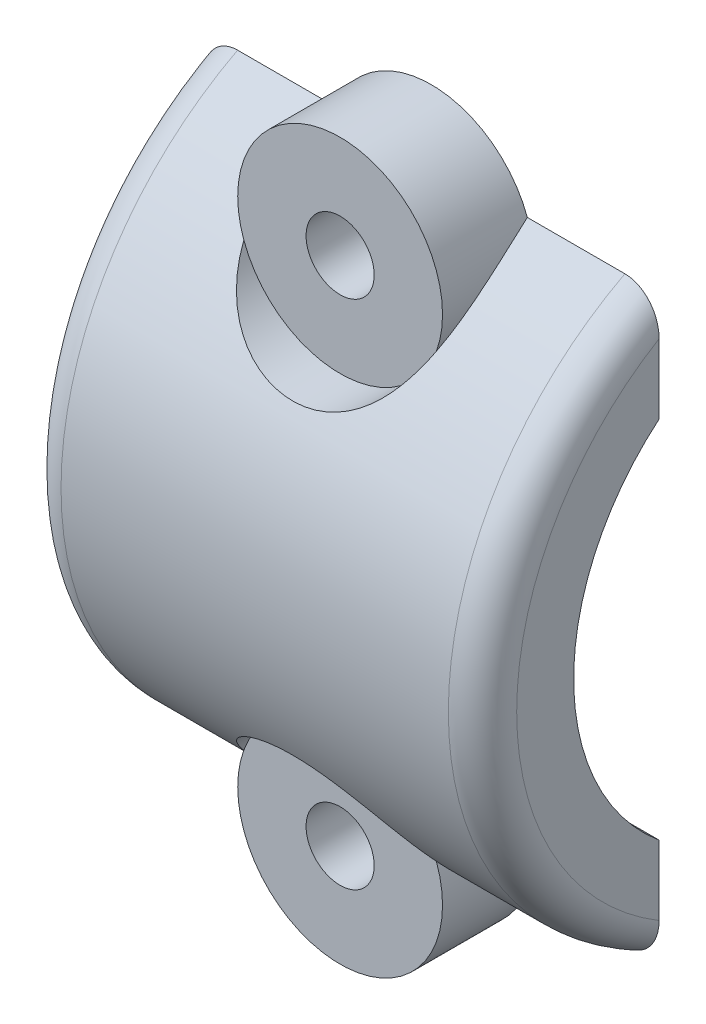
from build123d import *

# Parameters (mm, degrees)
BOSS_EXTRUDE2_DEPTH = 25.4
CUT_EXTRUDE7_START  = -1
SKETCH5_5_R         = 1.89865
CUT_EXTRUDE7_DEPTH  = 11.8425
SKETCH8_R           = 5.70865
SKETCH8_R_2         = 1.89865
BOSS_EXTRUDE4_DEPTH = 5.08
CUT_EXTRUDE8_START  = 5.08
SKETCH8_3_R         = 5.70865
SKETCH8_3_R_2       = 1.89865
CUT_EXTRUDE8_DEPTH  = 5.7625001
CUT_EXTRUDE3_DEPTH  = 26.4000001
FILLET3_R           = 1.905


with BuildPart() as part:
    # Sketch4 → Boss-Extrude2 (new body)
    with BuildSketch(Plane(origin=(-23.495, 41.0349954, 0), x_dir=(0, 0, 1), z_dir=(-1, 0, 0))):
        with BuildLine():
            ThreePointArc((0, 16.227532365), (9.8425, 0), (0, -16.227532365))
            Line((0, -16.227532365), (0, -10.16))
            ThreePointArc((0, -10.16), (4.7625, 0), (0, 10.16))
            Line((0, 10.16), (0, 16.227532365))
        make_face()
    extrude(amount=-BOSS_EXTRUDE2_DEPTH)

    # Sketch5_5 → Cut-Extrude7 (cut)
    with BuildSketch(Plane.XY.offset(CUT_EXTRUDE7_START)):
        with Locations((-10.795, 55.2907454)):
            Circle(SKETCH5_5_R)
    cut_extrude7 = extrude(amount=CUT_EXTRUDE7_DEPTH, mode=Mode.SUBTRACT)

    # Sketch8 → Boss-Extrude4 (add)
    with BuildSketch(Plane.XY):
        with Locations((-10.795, 55.2907454)):
            Circle(SKETCH8_R)
        with Locations((-10.795, 55.2907454)):
            Circle(SKETCH8_R_2, mode=Mode.SUBTRACT)
    boss_extrude4 = extrude(amount=BOSS_EXTRUDE4_DEPTH)

    # Sketch8_3 → Cut-Extrude8 (cut, through all)
    with BuildSketch(Plane.XY.offset(CUT_EXTRUDE8_START)):
        with Locations((-10.795, 55.2907454)):
            Circle(SKETCH8_3_R)
        with Locations((-10.795, 55.2907454)):
            Circle(SKETCH8_3_R_2, mode=Mode.SUBTRACT)
    cut_extrude8 = extrude(amount=CUT_EXTRUDE8_DEPTH, mode=Mode.SUBTRACT)

    # Mirror1: Cut-Extrude7, Boss-Extrude4, Cut-Extrude8 across plane
    add(cut_extrude7.mirror(Plane.ZX.offset(41.0349954)), mode=Mode.SUBTRACT)
    add(boss_extrude4.mirror(Plane.ZX.offset(41.0349954)))
    add(cut_extrude8.mirror(Plane.ZX.offset(41.0349954)), mode=Mode.SUBTRACT)

    # Sketch4_3 → Cut-Extrude3 (cut, through all)
    with BuildSketch(Plane(origin=(-23.495, 41.0349954, 0), x_dir=(0, 0, 1), z_dir=(-1, 0, 0))):
        with BuildLine():
            ThreePointArc((0, 10.16), (4.7625, 0), (0, -10.16))
            Line((0, -10.16), (0, 10.16))
        make_face()
    extrude(amount=-CUT_EXTRUDE3_DEPTH, mode=Mode.SUBTRACT)

    # Fillet3
    fillet3_edges = [part.edges().sort_by_distance(p)[0] for p in [
        (1.905, 41.0349954, 9.8425),
        (-23.495, 41.0349954, 9.8425),
    ]]
    fillet(fillet3_edges, radius=FILLET3_R)


solid = part.part
